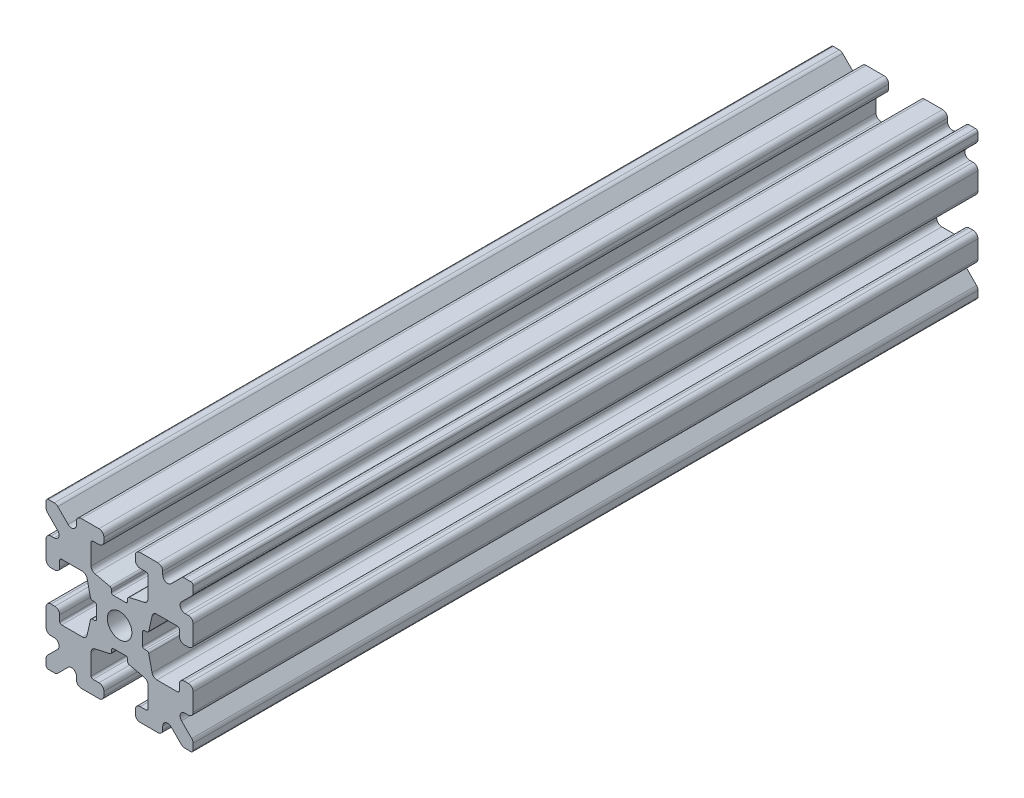
from build123d import *

# Parameters (mm, degrees)
SKETCH1_W           = 15
SKETCH1_H           = 15
SKETCH1_R           = 1.25
BOSS_EXTRUDE1_DEPTH = 40
FILLET1_R           = 0.25
CUT_EXTRUDE1_DEPTH  = 81
CUT_EXTRUDE3_DEPTH  = 81
FILLET3_R           = 0.5
FILLET4_R           = 0.5
FILLET5_R           = 3
FILLET6_R           = 0.2
CUT_EXTRUDE4_DEPTH  = 81
FILLET8_R           = 0.5
SKETCH6_W           = 5.1529354
SKETCH6_H           = 1.651
SKETCH6_W_2         = 1.651
SKETCH6_H_2         = 5.1529354
CUT_EXTRUDE5_DEPTH  = 81
FILLET10_R          = 0.2


with BuildPart() as part:
    # Sketch1 → Boss-Extrude1 (new body, symmetric)
    with BuildSketch(Plane.XY):
        Rectangle(SKETCH1_W, SKETCH1_H)
        Circle(SKETCH1_R, mode=Mode.SUBTRACT)
    extrude(amount=BOSS_EXTRUDE1_DEPTH, both=True)

    # Fillet1
    fillet1_edges = [part.edges().sort_by_distance(p)[0] for p in [
        (7.5, -7.5, 0),
        (-7.5, -7.5, 0),
        (-7.5, 7.5, 0),
        (7.5, 7.5, 0),
    ]]
    fillet(fillet1_edges, radius=FILLET1_R)

    # Sketch2 → Cut-Extrude1 (cut, through all)
    with BuildSketch(Plane.XY.offset(40)):
        Polygon((-7.5, 1.6), (-6.1, 1.6), (-6.1, 2.9), (-3.4, 2.9), (-3.4, -2.9), (-6.1, -2.9), (-6.1, -1.6), (-7.5, -1.6), align=None)
        Polygon((2.9, 6.1), (1.6, 6.1), (1.6, 7.5), (-1.6, 7.5), (-1.6, 6.1), (-2.9, 6.1), (-2.9, 3.4), (2.9, 3.4), align=None)
        Polygon((-1.6, -7.5), (-1.6, -6.1), (-2.9, -6.1), (-2.9, -3.4), (2.9, -3.4), (2.9, -6.1), (1.6, -6.1), (1.6, -7.5), align=None)
        Polygon((6.1, -2.9), (6.1, -1.6), (7.5, -1.6), (7.5, 1.6), (6.1, 1.6), (6.1, 2.9), (3.4, 2.9), (3.4, -2.9), align=None)
    extrude(amount=-CUT_EXTRUDE1_DEPTH, mode=Mode.SUBTRACT)

    # Sketch4 → Cut-Extrude3 (cut, through all)
    with BuildSketch(Plane.XY.offset(40)):
        Polygon((-3.4, 2.9), (-2.75, 0), (-3.4, -2.9), align=None)
        Polygon((-2.9, 3.4), (0, 2.75), (2.9, 3.4), align=None)
        Polygon((3.4, 2.9), (2.75, 0), (3.4, -2.9), align=None)
        Polygon((-2.9, -3.4), (0, -2.75), (2.9, -3.4), align=None)
    extrude(amount=-CUT_EXTRUDE3_DEPTH, mode=Mode.SUBTRACT)

    # Fillet3
    fillet3_edges = [part.edges().sort_by_distance(p)[0] for p in [
        (1.6, -7.5, 0),
        (-1.6, -7.5, 0),
        (-1.6, -6.1, 0),
        (1.6, -6.1, 0),
        (6.1, 1.6, 0),
        (7.5, 1.6, 0),
        (7.5, -1.6, 0),
        (6.1, -1.6, 0),
        (-7.5, -1.6, 0),
        (-7.5, 1.6, 0),
        (-6.1, 1.6, 0),
        (-6.1, -1.6, 0),
        (-1.6, 6.1, 0),
        (-1.6, 7.5, 0),
        (1.6, 7.5, 0),
        (1.6, 6.1, 0),
    ]]
    fillet(fillet3_edges, radius=FILLET3_R)

    # Fillet4
    fillet4_edges = [part.edges().sort_by_distance(p)[0] for p in [
        (-2.9, -3.4, 0),
        (2.9, -3.4, 0),
        (3.4, -2.9, 0),
        (3.4, 2.9, 0),
        (-3.4, 2.9, 0),
        (-3.4, -2.9, 0),
        (2.9, 3.4, 0),
        (-2.9, 3.4, 0),
    ]]
    fillet(fillet4_edges, radius=FILLET4_R)

    # Fillet5
    fillet5_edges = [part.edges().sort_by_distance(p)[0] for p in [
        (-2.75, 0, 0),
        (0, 2.75, 0),
        (2.75, 0, 0),
        (0, -2.75, 0),
    ]]
    fillet(fillet5_edges, radius=FILLET5_R)

    # Fillet6
    fillet6_edges = [part.edges().sort_by_distance(p)[0] for p in [
        (-2.9, -6.1, 0),
        (2.9, -6.1, 0),
        (6.1, -2.9, 0),
        (6.1, 2.9, 0),
        (-6.1, 2.9, 0),
        (-6.1, -2.9, 0),
        (2.9, 6.1, 0),
        (-2.9, 6.1, 0),
    ]]
    fillet(fillet6_edges, radius=FILLET6_R)

    # Sketch5 → Cut-Extrude4 (cut, through all)
    with BuildSketch(Plane.XY.offset(40)):
        Polygon((-7.5, 6.439339828), (-5.460660172, 4.4), (-7.5, 4.4), align=None)
        Polygon((-6.439339828, 7.5), (-4.4, 5.460660172), (-4.4, 7.5), align=None)
        Polygon((4.4, 7.5), (6.439339828, 7.5), (4.4, 5.460660172), align=None)
        Polygon((7.5, 6.439339828), (7.5, 4.4), (5.460660172, 4.4), align=None)
        Polygon((7.5, -6.439339828), (5.460660172, -4.4), (7.5, -4.4), align=None)
        Polygon((6.439339828, -7.5), (4.4, -5.460660172), (4.4, -7.5), align=None)
        Polygon((-4.4, -7.5), (-6.439339828, -7.5), (-4.4, -5.460660172), align=None)
        Polygon((-7.5, -6.439339828), (-7.5, -4.4), (-5.460660172, -4.4), align=None)
    extrude(amount=-CUT_EXTRUDE4_DEPTH, mode=Mode.SUBTRACT)

    # Fillet8
    fillet8_edges = [part.edges().sort_by_distance(p)[0] for p in [
        (-7.5, 4.4, 0),
        (-7.5, 6.439339828, 0),
        (-5.460660172, 4.4, 0),
        (7.5, -4.4, 0),
        (7.5, -6.439339828, 0),
        (5.460660172, -4.4, 0),
        (5.460660172, 4.4, 0),
        (7.5, 6.439339828, 0),
        (7.5, 4.4, 0),
        (-4.4, 7.5, 0),
        (-4.4, 5.460660172, 0),
        (-6.439339828, 7.5, 0),
        (-5.460660172, -4.4, 0),
        (-7.5, -6.439339828, 0),
        (-7.5, -4.4, 0),
        (4.4, 5.460660172, 0),
        (4.4, 7.5, 0),
        (6.439339828, 7.5, 0),
        (6.439339828, -7.5, 0),
        (4.4, -7.5, 0),
        (4.4, -5.460660172, 0),
        (-6.439339828, -7.5, 0),
        (-4.4, -5.460660172, 0),
        (-4.4, -7.5, 0),
    ]]
    fillet(fillet8_edges, radius=FILLET8_R)

    # Sketch6 → Cut-Extrude5 (cut, through all)
    with BuildSketch(Plane.XY.offset(40)):
        with Locations((4.9235323, 0)):
            Rectangle(SKETCH6_W, SKETCH6_H)
        with Locations((0, -4.9235323)):
            Rectangle(SKETCH6_W_2, SKETCH6_H_2)
        with Locations((-4.9235323, 0)):
            Rectangle(SKETCH6_W, SKETCH6_H)
        with Locations((0, 4.9235323)):
            Rectangle(SKETCH6_W_2, SKETCH6_H_2)
    extrude(amount=-CUT_EXTRUDE5_DEPTH, mode=Mode.SUBTRACT)

    # Fillet10
    fillet10_edges = [part.edges().sort_by_distance(p)[0] for p in [
        (0.8255, -2.935025862, 0),
        (-0.8255, -2.935025862, 0),
        (0.8255, -2.3470646, 0),
        (-0.8255, -2.3470646, 0),
        (2.935025862, 0.8255, 0),
        (2.935025862, -0.8255, 0),
        (2.3470646, 0.8255, 0),
        (2.3470646, -0.8255, 0),
        (-2.935025862, -0.8255, 0),
        (-2.935025862, 0.8255, 0),
        (-2.3470646, -0.8255, 0),
        (-2.3470646, 0.8255, 0),
        (-0.8255, 2.935025862, 0),
        (0.8255, 2.935025862, 0),
        (-0.8255, 2.3470646, 0),
        (0.8255, 2.3470646, 0),
    ]]
    fillet(fillet10_edges, radius=FILLET10_R)


solid = part.part
